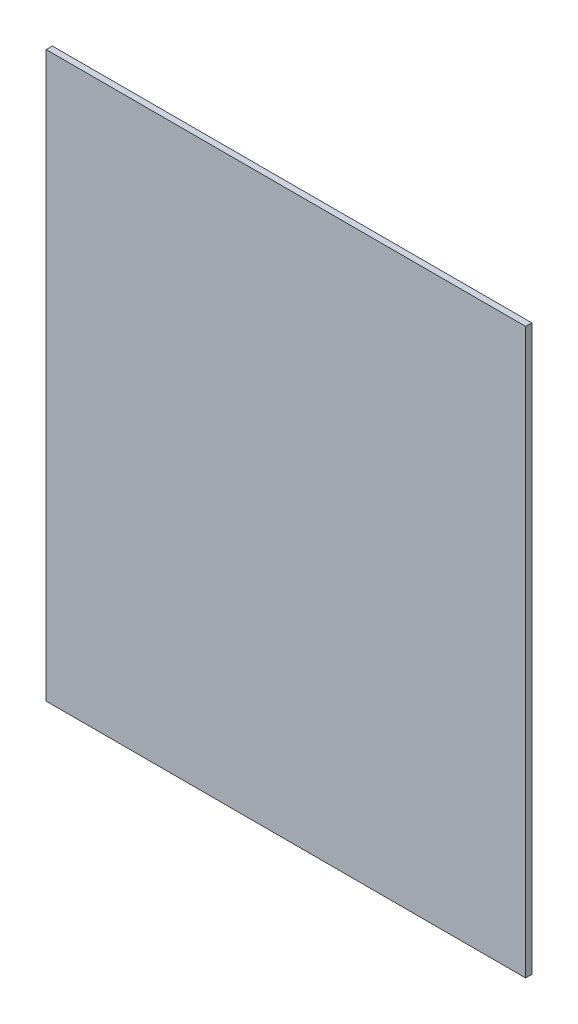
from build123d import *

# Parameters (mm, degrees)
ESQUISSE1_W        = 77.5
ESQUISSE1_H        = 91.2
BOSS_EXTRU_1_DEPTH = 1


with BuildPart() as part:
    # Esquisse1 → Boss.-Extru.1 (new body)
    with BuildSketch(Plane.XY):
        with Locations((38.75, 45.6)):
            Rectangle(ESQUISSE1_W, ESQUISSE1_H)
    extrude(amount=BOSS_EXTRU_1_DEPTH)


solid = part.part
